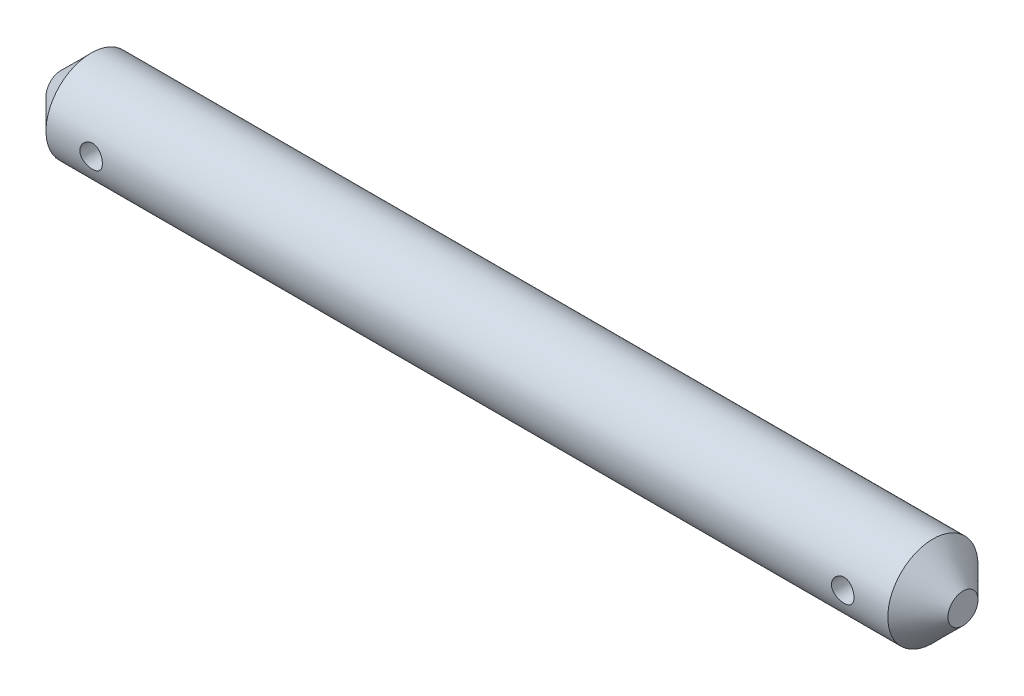
from build123d import *

# Parameters (mm, degrees)
SKETCH_1_R               = 3
EXTRUDE_1_DEPTH          = 60
CHAMFER_1_SIZE           = 2
SKETCH_2_R               = 0.75
CUT_EXTRUDE_1_DEPTH      = 4
CUT_EXTRUDE_1_DEPTH_BACK = 4


with BuildPart() as part:
    # Эскиз1 → Бобышка-Вытянуть1 (new body)
    with BuildSketch(Plane(origin=(0, 0, 0), x_dir=(0, 0, -1), z_dir=(1, 0, 0))):
        Circle(SKETCH_1_R)
    extrude(amount=EXTRUDE_1_DEPTH)

    # Фаска1
    chamfer_1_edges = [part.edges().sort_by_distance(p)[0] for p in [
        (0, 0, 3),
        (60, 0, 3),
    ]]
    chamfer(chamfer_1_edges, length=CHAMFER_1_SIZE)

    # Эскиз2 → Вырез-Вытянуть1 (cut, two sides)
    with BuildSketch(Plane.XY) as cut_extrude_1_sk:
        with Locations((5, 0)):
            Circle(SKETCH_2_R)
        with Locations((55, 0)):
            Circle(SKETCH_2_R)
    extrude(amount=CUT_EXTRUDE_1_DEPTH, mode=Mode.SUBTRACT)
    extrude(cut_extrude_1_sk.sketch, amount=-CUT_EXTRUDE_1_DEPTH_BACK, mode=Mode.SUBTRACT)


solid = part.part
